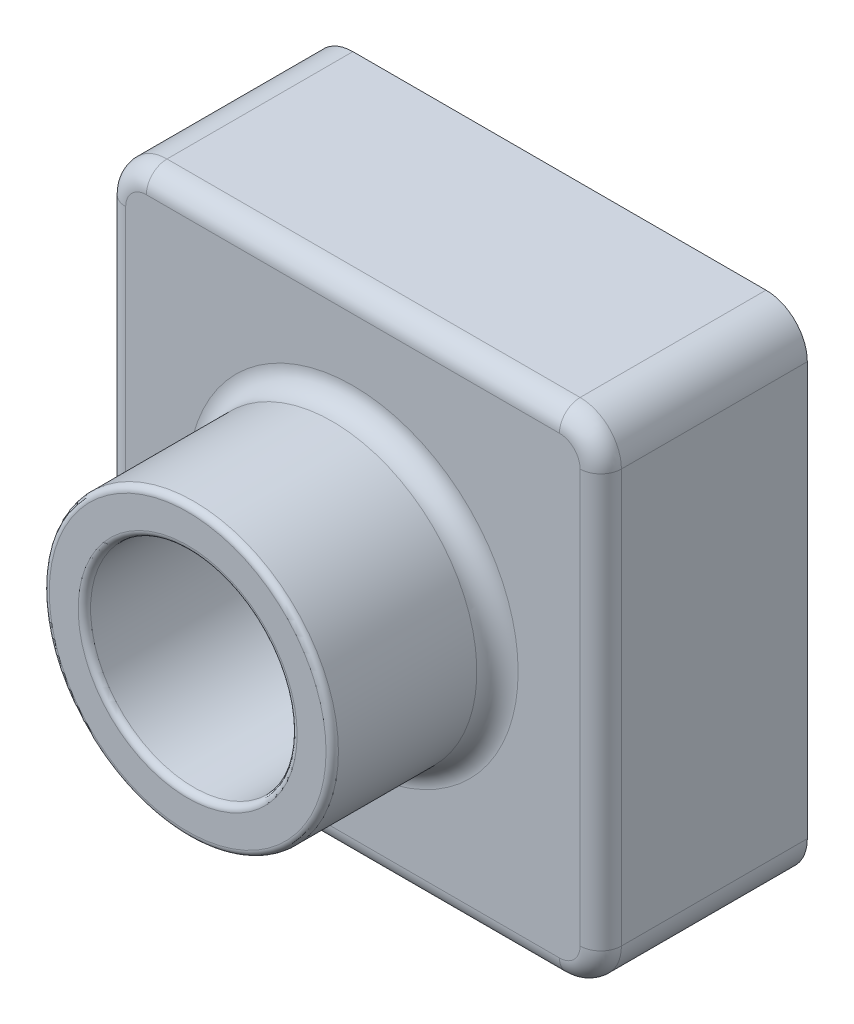
from build123d import *

# Parameters (mm, degrees)
SKETCH1_W           = 120
SKETCH1_H           = 120
BOSS_EXTRUDE1_DEPTH = 50
SKETCH3_R           = 35
BOSS_EXTRUDE2_DEPTH = 40
SKETCH4_R           = 25
CUT_EXTRUDE1_DEPTH  = 91
FILLET1_R           = 10
FILLET2_R           = 1.5
FILLET5_R           = 5
SHELL1_T            = -2


with BuildPart() as part:
    # Sketch1 → Boss-Extrude1 (new body)
    with BuildSketch(Plane.XY):
        with Locations((60, 60)):
            Rectangle(SKETCH1_W, SKETCH1_H)
    extrude(amount=BOSS_EXTRUDE1_DEPTH)

    # Sketch3 → Boss-Extrude2 (add)
    with BuildSketch(Plane.XY.offset(50)):
        with Locations((60, 60)):
            Circle(SKETCH3_R)
    extrude(amount=BOSS_EXTRUDE2_DEPTH)

    # Sketch4 → Cut-Extrude1 (cut, through all)
    with BuildSketch(Plane.XY.offset(90)):
        with Locations((60, 60)):
            Circle(SKETCH4_R)
    extrude(amount=-CUT_EXTRUDE1_DEPTH, mode=Mode.SUBTRACT)

    # Fillet1
    fillet1_edges = [part.edges().sort_by_distance(p)[0] for p in [
        (0, 120, 25),
        (120, 120, 25),
        (120, 0, 25),
        (0, 0, 25),
    ]]
    fillet(fillet1_edges, radius=FILLET1_R)

    # Fillet2
    fillet2_edges = [part.edges().sort_by_distance(p)[0] for p in [
        (25, 60, 90),
        (35, 60, 90),
    ]]
    fillet(fillet2_edges, radius=FILLET2_R)

    # Fillet5
    fillet5_edges = [part.edges().sort_by_distance(p)[0] for p in [
        (25, 60, 50),
        (60, 120, 50),
        (120, 60, 50),
        (0, 60, 50),
        (60, 0, 50),
        (117.071067812, 2.928932188, 50),
        (2.928932188, 117.071067812, 50),
        (2.928932188, 2.928932188, 50),
        (117.071067812, 117.071067812, 50),
    ]]
    fillet(fillet5_edges, radius=FILLET5_R)

    # Shell1
    shell1_openings = [part.faces().sort_by_distance(p)[0] for p in [
        (85, 60, 0),
    ]]
    offset(amount=SHELL1_T, openings=shell1_openings, kind=Kind.INTERSECTION)


solid = part.part
